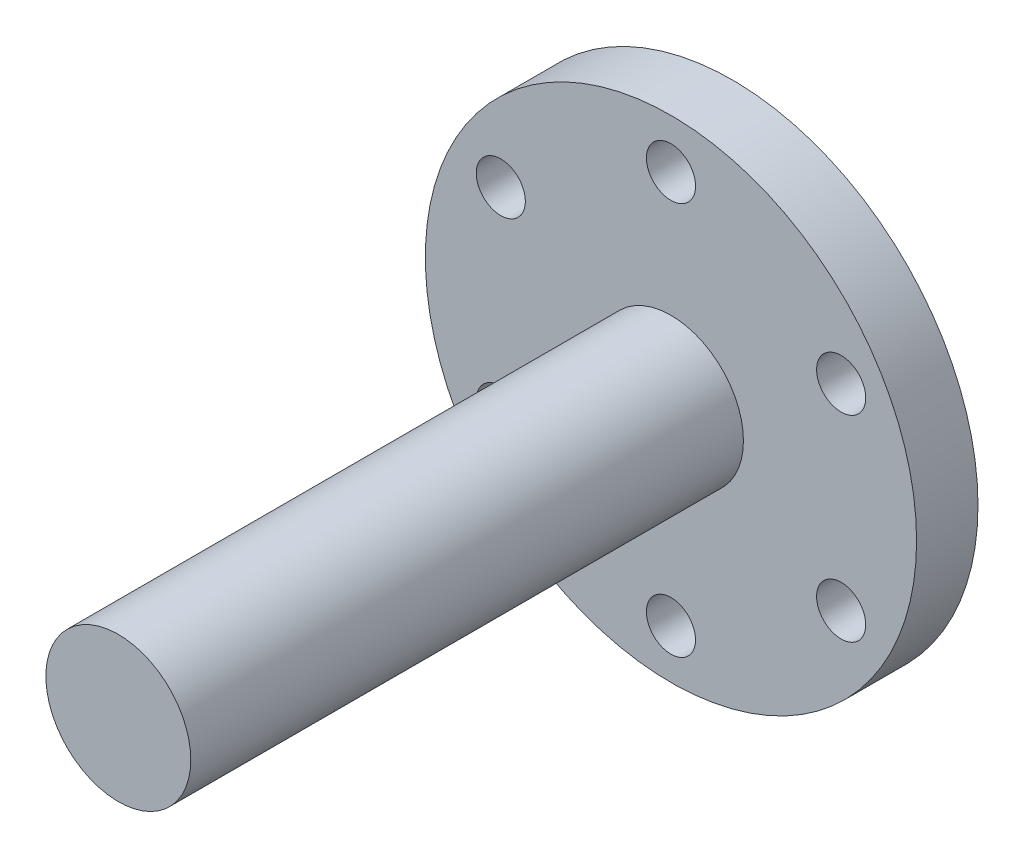
from build123d import *

# Parameters (mm, degrees)
SKETCH1_R           = 20
BOSS_EXTRUDE1_DEPTH = 5
SKETCH2_R           = 5.9
BOSS_EXTRUDE2_DEPTH = 45
SKETCH3_R           = 2
CUT_EXTRUDE1_DEPTH  = 5


with BuildPart() as part:
    # Sketch1 → Boss-Extrude1 (new body)
    with BuildSketch(Plane.XY):
        Circle(SKETCH1_R)
    extrude(amount=BOSS_EXTRUDE1_DEPTH)

    # Sketch2 → Boss-Extrude2 (add)
    with BuildSketch(Plane.XY.offset(5)):
        Circle(SKETCH2_R)
    extrude(amount=BOSS_EXTRUDE2_DEPTH)

    # Sketch3 → Cut-Extrude1 (cut)
    with BuildSketch(Plane.XY.offset(5)):
        with Locations((0, 16)):
            Circle(SKETCH3_R)
        with Locations((13.856406461, 8)):
            Circle(SKETCH3_R)
        with Locations((13.856406461, -8)):
            Circle(SKETCH3_R)
        with Locations((0, -16)):
            Circle(SKETCH3_R)
        with Locations((-13.856406461, -8)):
            Circle(SKETCH3_R)
        with Locations((-13.856406461, 8)):
            Circle(SKETCH3_R)
    extrude(amount=-CUT_EXTRUDE1_DEPTH, mode=Mode.SUBTRACT)


solid = part.part
